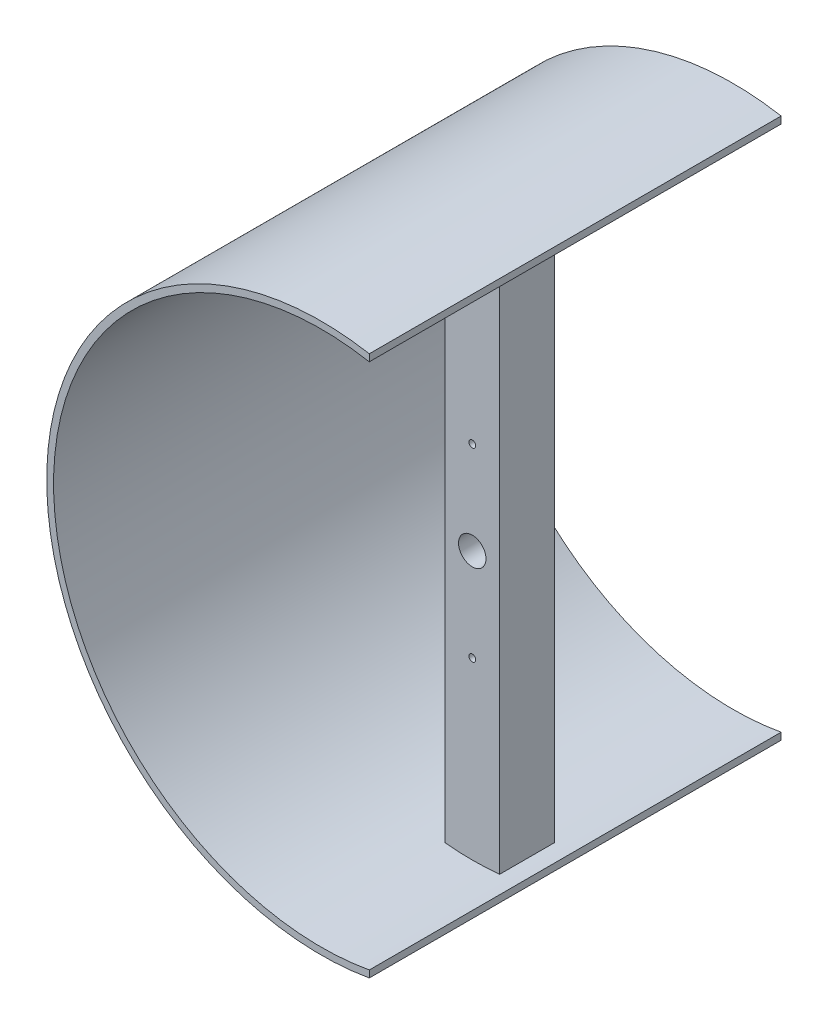
from build123d import *

# Parameters (mm, degrees)
ESQUISSE1_W              = 8
ESQUISSE1_H              = 79
BOSS_EXTRU_1_DEPTH       = 60
ESQUISSE3_R              = 40
ESQUISSE3_R_2            = 39
BOSS_EXTRU_2_DEPTH       = 60
ESQUISSE4_R              = 39
ENL_V_MAT_EXTRU_3_DEPTH  = 30
ENL_V_MAT_EXTRU_5_DEPTH  = 1.5
ESQUISSE6_R              = 39
ENL_V_MAT_EXTRU_6_DEPTH  = 22
ESQUISSE7_R              = 2
ENL_V_MAT_EXTRU_7_DEPTH  = 6.5
ESQUISSE9_R              = 0.5
ENL_V_MAT_EXTRU_8_DEPTH  = 29.5
ENL_V_MAT_EXTRU_10_REACH = 62
ESQUISSE11_W             = 40
ESQUISSE11_H             = 82


with BuildPart() as part:
    # Esquisse1 → Boss.-Extru.1 (new body)
    with BuildSketch(Plane.XY):
        with Locations((4, 39.5)):
            Rectangle(ESQUISSE1_W, ESQUISSE1_H)
    extrude(amount=BOSS_EXTRU_1_DEPTH)

    # Esquisse3 → Boss.-Extru.2 (add)
    with BuildSketch(Plane(origin=(0, 0, 0), x_dir=(-1, 0, 0), z_dir=(0, 0, -1))):
        with Locations((-4, 39.5)):
            Circle(ESQUISSE3_R)
        with Locations((-4, 39.5)):
            Circle(ESQUISSE3_R_2, mode=Mode.SUBTRACT)
    extrude(amount=-BOSS_EXTRU_2_DEPTH)

    # Esquisse4 → Enlèv. mat.-Extru.3 (cut)
    with BuildSketch(Plane(origin=(0, 0, 0), x_dir=(-1, 0, 0), z_dir=(0, 0, -1))):
        with Locations((-4, 39.5)):
            Circle(ESQUISSE4_R)
    extrude(amount=-ENL_V_MAT_EXTRU_3_DEPTH, mode=Mode.SUBTRACT)

    # Esquisse5 → Enlèv. mat.-Extru.5 (cut)
    with BuildSketch(Plane(origin=(0, 0, 30), x_dir=(-1, 0, 0), z_dir=(0, 0, -1))):
        with BuildLine():
            Line((-6, 53), (-6.967257844, 39.9420191))
            ThreePointArc((-6.967257844, 39.9420191), (-7, 39.5), (-6.967257844, 39.0579809))
            Line((-6.967257844, 39.0579809), (-6, 26))
            ThreePointArc((-6, 26), (-4, 24), (-2, 26))
            Line((-2, 26), (-1.032742156, 39.0579809))
            ThreePointArc((-1.032742156, 39.0579809), (-1, 39.5), (-1.032742156, 39.9420191))
            Line((-1.032742156, 39.9420191), (-2, 53))
            ThreePointArc((-2, 53), (-4, 55), (-6, 53))
        make_face()
    extrude(amount=-ENL_V_MAT_EXTRU_5_DEPTH, mode=Mode.SUBTRACT)

    # Esquisse6 → Enlèv. mat.-Extru.6 (cut)
    with BuildSketch(Plane.XY.offset(60)):
        with Locations((4, 39.5)):
            Circle(ESQUISSE6_R)
    extrude(amount=-ENL_V_MAT_EXTRU_6_DEPTH, mode=Mode.SUBTRACT)

    # Esquisse7 → Enlèv. mat.-Extru.7 (cut)
    with BuildSketch(Plane(origin=(0, 0, 31.5), x_dir=(-1, 0, 0), z_dir=(0, 0, -1))):
        with Locations((-4, 39.5)):
            Circle(ESQUISSE7_R)
    extrude(amount=-ENL_V_MAT_EXTRU_7_DEPTH, mode=Mode.SUBTRACT)

    # Esquisse9 → Enlèv. mat.-Extru.8 (cut, through all)
    with BuildSketch(Plane(origin=(0, 0, 31.5), x_dir=(-1, 0, 0), z_dir=(0, 0, -1))):
        with Locations((-4, 53)):
            Circle(ESQUISSE9_R)
        with Locations((-4, 26)):
            Circle(ESQUISSE9_R)
    extrude(amount=-ENL_V_MAT_EXTRU_8_DEPTH, mode=Mode.SUBTRACT)

    # Esquisse11 → Enlèv. mat.-Extru.10 (cut, up to next)
    with BuildSketch(Plane.XY, mode=Mode.PRIVATE) as enl_v_mat_extru_10_sk1:
        with Locations((31, 39.5)):
            Rectangle(ESQUISSE11_W, ESQUISSE11_H)
    enl_v_mat_extru_10_tool1 = extrude(enl_v_mat_extru_10_sk1.sketch, amount=ENL_V_MAT_EXTRU_10_REACH, mode=Mode.PRIVATE) & part.part
    add(enl_v_mat_extru_10_tool1.solids().sort_by_distance((31, 39.5, 0))[0], mode=Mode.SUBTRACT)


solid = part.part
